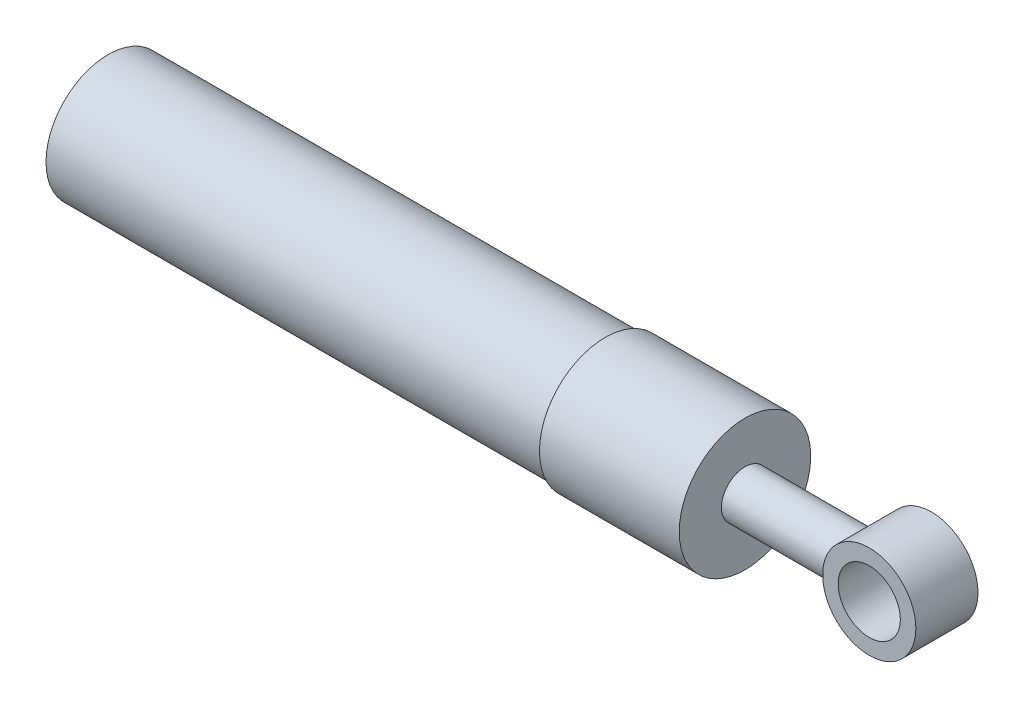
from build123d import *

# Parameters (mm, degrees)
SKETCH3_R           = 4.7625
SKETCH3_R_2         = 3.175
BOSS_EXTRUDE1_DEPTH = 3.175


with BuildPart() as part:
    # Sketch2 → Revolve1 (revolve)
    with BuildSketch(Plane.XY):
        Polygon((0, 0), (0, 6.35), (50.8, 6.35), (50.8, 6.7183), (65.0875, 6.7183), (65.0875, 2.413), (77.7875, 2.413), (77.7875, 0), align=None)
    revolve(axis=Axis((0, 0, 0), (1, 0, 0)))

    # Sketch3 → Boss-Extrude1 (add, symmetric)
    with BuildSketch(Plane.XY):
        with Locations((80.9625, 0)):
            Circle(SKETCH3_R)
        with Locations((80.9625, 0)):
            Circle(SKETCH3_R_2, mode=Mode.SUBTRACT)
    extrude(amount=BOSS_EXTRUDE1_DEPTH, both=True)


solid = part.part
